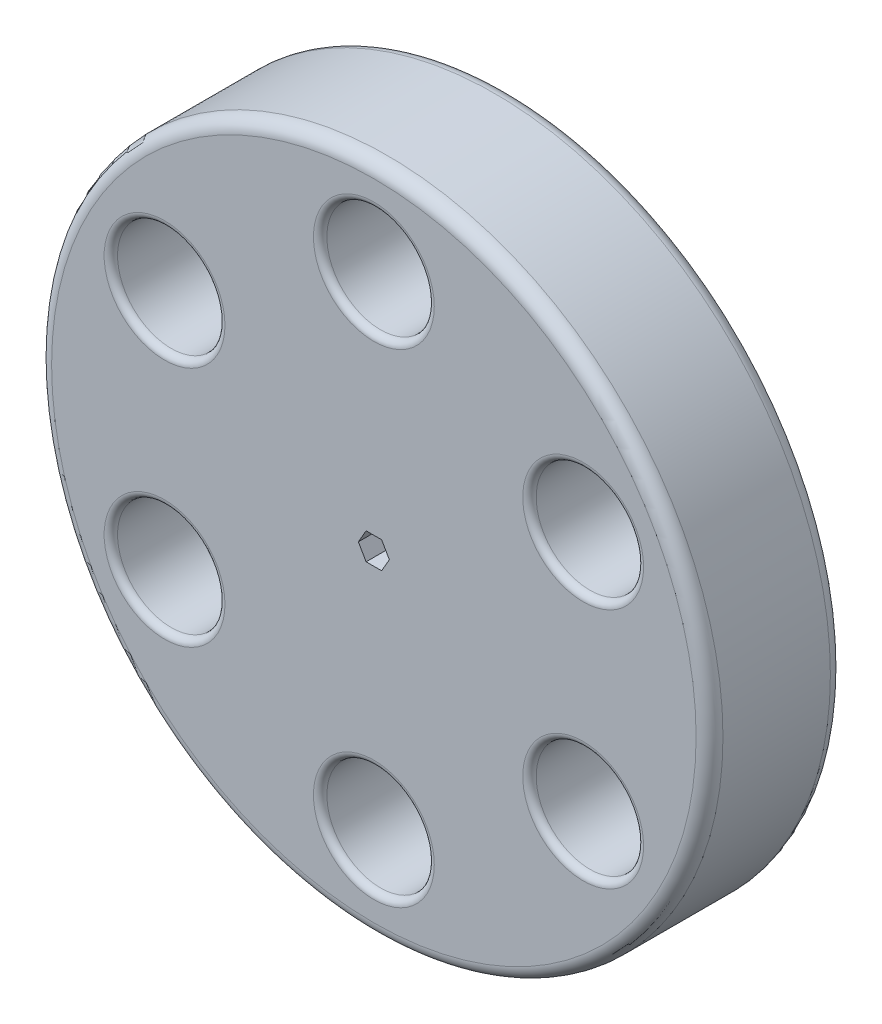
from build123d import *

# Parameters (mm, degrees)
SKETCH1_R           = 25
BOSS_EXTRUDE1_DEPTH = 10
SKETCH3_R           = 4
CUT_EXTRUDE3_DEPTH  = 11
CIRPATTERN1_COUNT   = 6
FILLET1_R           = 1
FILLET2_R           = 0.5
CUT_EXTRUDE4_DEPTH  = 10


with BuildPart() as part:
    # Sketch1 → Boss-Extrude1 (new body)
    with BuildSketch(Plane.XY):
        Circle(SKETCH1_R)
    extrude(amount=BOSS_EXTRUDE1_DEPTH)

    # Sketch3 → Cut-Extrude3 (cut, through all)
    with BuildSketch(Plane.XY.offset(10)):
        with Locations((0, 18)):
            Circle(SKETCH3_R)
    cut_extrude3 = extrude(amount=-CUT_EXTRUDE3_DEPTH, mode=Mode.SUBTRACT)

    # CirPattern1: Cut-Extrude3 ×6 about axis
    cirpattern1_axis = Axis((0, 0, 0), (0, 0, 1))
    for i in range(1, CIRPATTERN1_COUNT):
        add(cut_extrude3.rotate(cirpattern1_axis, i * 360 / CIRPATTERN1_COUNT), mode=Mode.SUBTRACT)

    # Fillet1
    fillet1_edges = [part.edges().sort_by_distance(p)[0] for p in [
        (-25, 0, 0),
        (-25, 0, 10),
    ]]
    fillet(fillet1_edges, radius=FILLET1_R)

    # Fillet2
    fillet2_edges = [part.edges().sort_by_distance(p)[0] for p in [
        (13.588457268, 12.464101615, 0),
        (13.588457268, 12.464101615, 10),
        (17.588457268, -5.535898385, 0),
        (17.588457268, -5.535898385, 10),
        (4, -18, 0),
        (4, -18, 10),
        (-13.588457268, -12.464101615, 0),
        (-13.588457268, -12.464101615, 10),
        (-17.588457268, 5.535898385, 0),
        (-17.588457268, 5.535898385, 10),
        (-4, 18, 0),
        (-4, 18, 10),
    ]]
    fillet(fillet2_edges, radius=FILLET2_R)

    # Sketch2 → Cut-Extrude4 (cut)
    with BuildSketch(Plane.XY.offset(10)):
        Polygon((1.154700538, 0), (0.577350269, 1), (-0.577350269, 1), (-1.154700538, 0), (-0.577350269, -1), (0.577350269, -1), align=None)
    extrude(amount=-CUT_EXTRUDE4_DEPTH, mode=Mode.SUBTRACT)


solid = part.part
